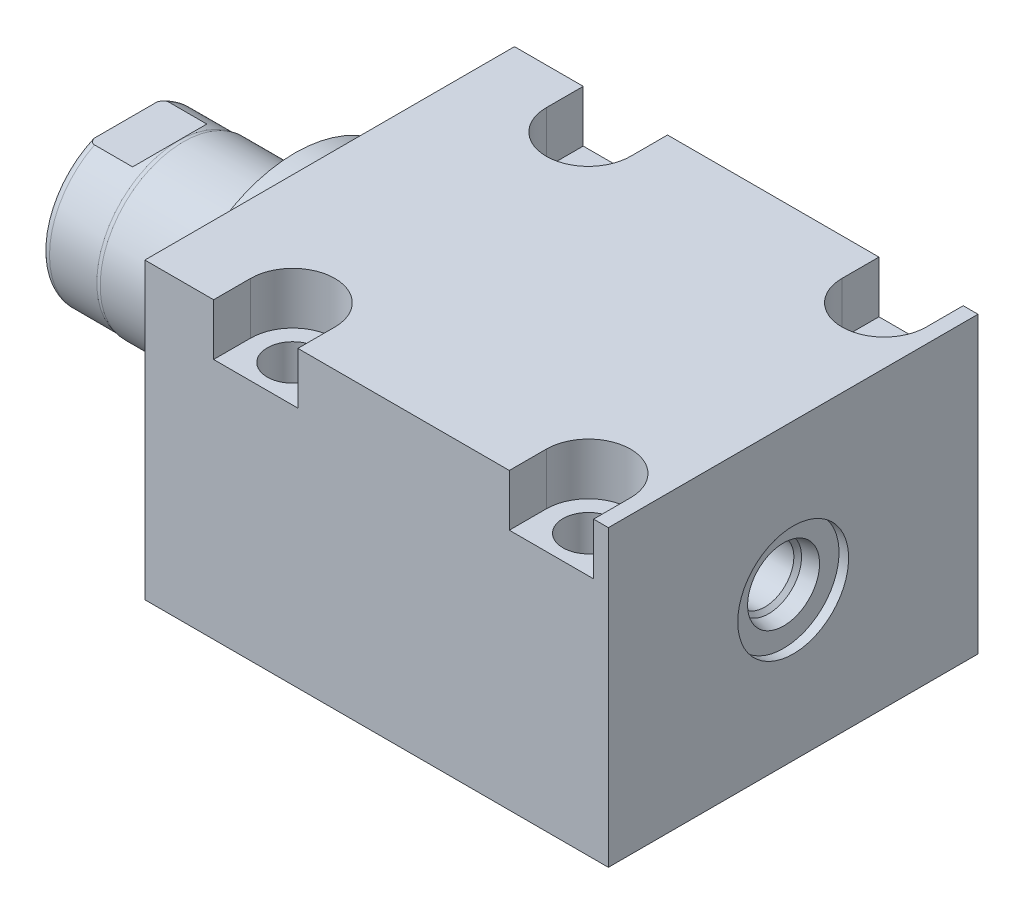
from build123d import *

# Parameters (mm, degrees)
SKETCH1_W          = 63.5
SKETCH1_H          = 50.546
EXTRUDE1_DEPTH     = 79.629
SKETCH5_R          = 22.225
EXTRUDE2_DEPTH     = 5.969
SKETCH6_W          = 14.2875
SKETCH6_H          = 29.083
CUT_EXTRUDE4_DEPTH = 30.48
HOLE2_D            = 8.7376
HOLE2_DEPTH        = 50.546
LPATTERN1_COUNT    = 2
LPATTERN1_PITCH    = 50.8
CUT_EXTRUDE5_DEPTH = 8.89
HOLE3_D            = 3.175
HOLE3_DEPTH        = 9.525
HOLE3_CBORE_D      = 11.3411
HOLE3_CBORE_DEPTH  = 1.4478
HOLE3_TIP          = 0.953866233
HOLE4_D            = 3.175
HOLE4_DEPTH        = 9.525
HOLE4_CBORE_D      = 11.3411
HOLE4_CBORE_DEPTH  = 1.4478
HOLE4_TIP          = 0.953866233
CHAMFER1_SIZE      = 0.635
SKETCH23_R         = 1.4478
LPATTERN3_COUNT    = 2
LPATTERN3_PITCH    = 50.8


with BuildPart() as part:
    # Sketch1 → Extrude1 (new body)
    with BuildSketch(Plane(origin=(0, 0, 0), x_dir=(0, 0, -1), z_dir=(1, 0, 0))):
        with Locations((0, -0.127)):
            Rectangle(SKETCH1_W, SKETCH1_H)
    extrude(amount=EXTRUDE1_DEPTH)

    # Sketch5 → Extrude2 (add)
    with BuildSketch(Plane.ZY):
        with Locations(Location((0, 0, 0), (0, 0, 180))):  # turned: the seam where the file's is
            Circle(SKETCH5_R)
    extrude(amount=EXTRUDE2_DEPTH)

    # Sketch6 → Revolve1 (revolve)
    with BuildSketch(Plane(origin=(0, 0, 0), x_dir=(0, 0, 1), z_dir=(0, -1, 0))):
        with Locations((-7.14375, 20.5105)):
            Rectangle(SKETCH6_W, SKETCH6_H)
    revolve(axis=Axis((5.754582971, 0, 0), (-1, 0, 0)))

    # S2D0001 → Cut-Revolve4 (revolve, cut)
    with BuildSketch(Plane(origin=(-18.511260017, 3.2639, 0), x_dir=(0, 1, 0), z_dir=(0, 0, 1)), mode=Mode.PRIVATE) as cut_revolve4_sk:
        Polygon((2.286, 14.473017728), (2.286, -1.950460017), (-3.2639, -1.950460017), (-3.2639, 16.540739983), (3.4798, 16.540739983), align=None)
    revolve(cut_revolve4_sk.sketch.rotate(Axis((0, 0, 0), (-1, 0, 0)), 90), axis=Axis((0, 0, 0), (-1, 0, 0)), mode=Mode.SUBTRACT)  # turned: the seam where the file's is

    # Sketch8 → Cut-Revolve5 (revolve, cut)
    with BuildSketch(Plane(origin=(0, 0, 0), x_dir=(0, 0, -1), z_dir=(0, 1, 0)), mode=Mode.PRIVATE) as cut_revolve5_sk:
        with BuildLine():
            Line((-14.2875, 25.146), (-14.097, 25.908))
            Line((-14.097, 25.908), (-14.097, 34.036))
            ThreePointArc((-14.097, 34.036), (-13.996678675, 34.579796865), (-13.708922533, 35.052))
            Line((-13.708922533, 35.052), (-14.2875, 35.052))
            Line((-14.2875, 35.052), (-14.2875, 25.146))
        make_face()
    revolve(cut_revolve5_sk.sketch.rotate(Axis((-12.65936, 0, 0), (-1, 0, 0)), 180), axis=Axis((-12.65936, 0, 0), (-1, 0, 0)), mode=Mode.SUBTRACT)  # turned: the seam where the file's is

    # Sketch12 → Cut-Extrude4 (cut, symmetric)
    with BuildSketch(Plane(origin=(0, 0, 0), x_dir=(0, -1, 0), z_dir=(0, 0, -1))):
        Polygon((12.573, 35.052), (12.573, 27.4828), (14.097, 25.9588), (14.097, 35.052), align=None)
        Polygon((-12.573, 35.052), (-12.573, 27.4828), (-14.097, 25.9588), (-14.097, 35.052), align=None)
    extrude(amount=CUT_EXTRUDE4_DEPTH, both=True, mode=Mode.SUBTRACT)

    # Hole2
    with Locations(Plane(origin=(0, 25.146, 0), x_dir=(-1, 0, 0), z_dir=(0, 1, 0))):
        with Locations((-19.05, -25.4), (-19.05, 25.4)):
            hole2 = Hole(HOLE2_D / 2, depth=HOLE2_DEPTH)

    # LPattern1: Hole2 ×2
    with Locations(*[(i * LPATTERN1_PITCH, 0, 0) for i in range(1, LPATTERN1_COUNT)]):
        add(hole2, mode=Mode.SUBTRACT)

    # Sketch18 → Cut-Extrude5 (cut)
    with BuildSketch(Plane(origin=(0, 25.146, 0), x_dir=(1, 0, 0), z_dir=(0, 1, 0))):
        with BuildLine():
            Line((77.089, -31.75), (62.611, -31.75))
            Line((62.611, -31.75), (62.611, -25.4))
            ThreePointArc((62.611, -25.4), (69.85, -18.161), (77.089, -25.4))
            Line((77.089, -25.4), (77.089, -31.75))
        make_face()
        with BuildLine():
            Line((11.811, -25.4), (11.811, -31.75))
            Line((11.811, -31.75), (26.289, -31.75))
            Line((26.289, -31.75), (26.289, -25.4))
            ThreePointArc((26.289, -25.4), (19.05, -18.161), (11.811, -25.4))
        make_face()
        with BuildLine():
            Line((77.089, 25.4), (77.089, 31.75))
            Line((77.089, 31.75), (62.611, 31.75))
            Line((62.611, 31.75), (62.611, 25.4))
            ThreePointArc((62.611, 25.4), (69.85, 18.161), (77.089, 25.4))
        make_face()
        with BuildLine():
            Line((26.289, 31.75), (11.811, 31.75))
            Line((11.811, 31.75), (11.811, 25.4))
            ThreePointArc((11.811, 25.4), (19.05, 18.161), (26.289, 25.4))
            Line((26.289, 25.4), (26.289, 31.75))
        make_face()
    extrude(amount=-CUT_EXTRUDE5_DEPTH, mode=Mode.SUBTRACT)

    # Hole3
    with Locations(Plane.XZ.offset(25.4)):
        with Locations((12.7, 0)):
            CounterBoreHole(HOLE3_D / 2, HOLE3_CBORE_D / 2, HOLE3_CBORE_DEPTH, depth=HOLE3_DEPTH)
            with Locations((0, 0, -(HOLE3_DEPTH + HOLE3_TIP / 2))):  # 118° drill point
                Cone(0, HOLE3_D / 2, HOLE3_TIP, mode=Mode.SUBTRACT)

    # Hole4
    with Locations(Plane.XZ.offset(25.4)):
        with Locations((63.5, 0)):
            CounterBoreHole(HOLE4_D / 2, HOLE4_CBORE_D / 2, HOLE4_CBORE_DEPTH, depth=HOLE4_DEPTH)
            with Locations((0, 0, -(HOLE4_DEPTH + HOLE4_TIP / 2))):  # 118° drill point
                Cone(0, HOLE4_D / 2, HOLE4_TIP, mode=Mode.SUBTRACT)

    # Chamfer1
    chamfer1_edges = [part.edges().sort_by_distance(p)[0] for p in [
        (14.2875, -23.9522, 0),
        (65.0875, -23.9522, 0),
    ]]
    chamfer(chamfer1_edges, length=CHAMFER1_SIZE)

    # Sketch24 → Cut-Revolve6 (revolve, cut)
    with BuildSketch(Plane.XY, mode=Mode.PRIVATE) as cut_revolve6_sk:
        Polygon((79.629, 9.525), (77.978, 9.525), (77.978, 6.1849), (75.4253, 5.642306865), (74.761393135, 4.9784), (63.373, 4.9784), (63.373, 0), (79.629, 0), align=None)
    revolve(cut_revolve6_sk.sketch.rotate(Axis((0, 0, 0), (1, 0, 0)), 270), axis=Axis((0, 0, 0), (1, 0, 0)), mode=Mode.SUBTRACT)  # turned: the seam where the file's is


with BuildPart() as body_2:
    # Sketch23 → Revolve2 (revolve)
    with BuildSketch(Plane.XY, mode=Mode.PRIVATE) as revolve2_sk:
        with Locations((8.47725, -25.4)):
            Circle(SKETCH23_R)
    revolve(revolve2_sk.sketch.rotate(Axis((12.7, -23.9522, 0), (0, 1, 0)), 270), axis=Axis((12.7, -23.9522, 0), (0, 1, 0)))  # turned: the seam where the file's is


with BuildPart() as lpattern3_1:
    # LPattern3: pattern copy
    add(body_2.part.moved(Location(Vector(1, 0, 0) * (1 * LPATTERN3_PITCH))))


solid = Compound([part.part, body_2.part, lpattern3_1.part])
